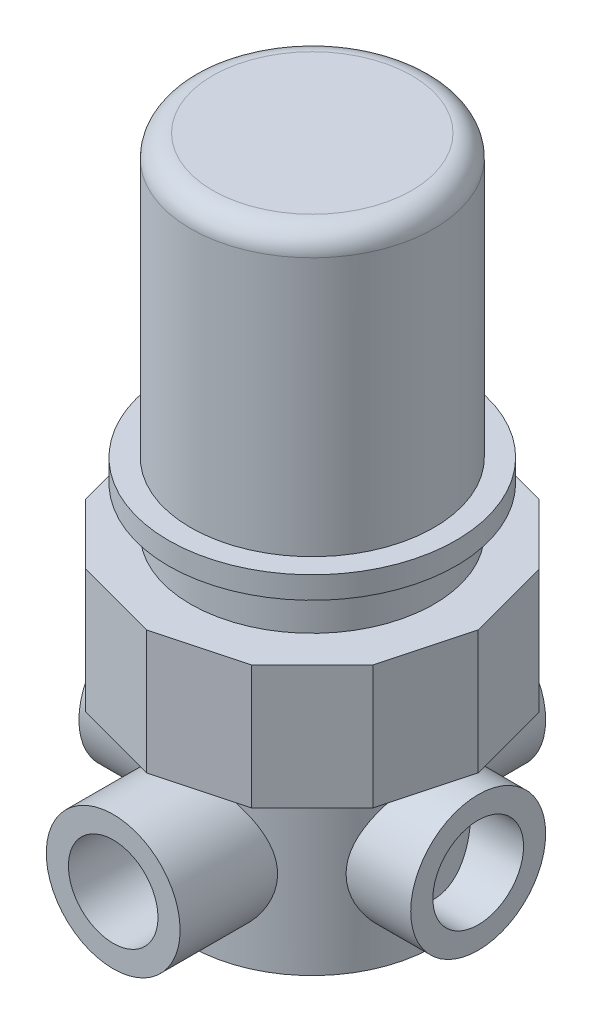
from build123d import *

# Parameters (mm, degrees)
CUT_EXTRUDE1_START       = -14.224
CUT_EXTRUDE1_DEPTH       = 14.224
SKETCH3_R                = 7.6835
SKETCH3_R_2              = 5.1435
BOSS_EXTRUDE1_DEPTH      = 8.89
BOSS_EXTRUDE1_DEPTH_BACK = 8.89
BOSS_EXTRUDE2_START      = -2.344817
SKETCH4_R                = 7.747
SKETCH4_R_2              = 5.207
BOSS_EXTRUDE2_DEPTH      = 7.424817
CIRPATTERN1_COUNT        = 4
FILLET1_R                = 2.54


with BuildPart() as part:
    # Sketch1 → Revolve1 (revolve)
    with BuildSketch(Plane.XY):
        Polygon((0, 73.914), (13.97, 73.914), (13.97, 41.656), (16.51, 41.656), (16.51, 39.116), (13.97, 39.116), (13.97, 34.036), (19.05, 34.036), (19.05, 19.812), (13.97, 19.812), (13.97, 0), (0, 0), align=None)
    revolve(axis=Axis((0, 73.914, 0), (0, -1, 0)))

    # Sketch2 → Cut-Extrude1 (cut)
    with BuildSketch(Plane(origin=(0, 34.036, 0), x_dir=(1, 0, 0), z_dir=(0, 1, 0)).offset(CUT_EXTRUDE1_START)):
        with BuildLine():
            ThreePointArc((9.525, 16.497783942), (4.930502809, 18.400886991), (0, 19.05))
            Line((0, 19.05), (9.525, 16.497783942))
        make_face()
        with BuildLine():
            Line((-9.525, 16.497783942), (0, 19.05))
            ThreePointArc((0, 19.05), (-4.930502809, 18.400886991), (-9.525, 16.497783942))
        make_face()
        with BuildLine():
            Line((-16.497783942, 9.525), (-9.525, 16.497783942))
            ThreePointArc((-9.525, 16.497783942), (-13.470384182, 13.470384182), (-16.497783942, 9.525))
        make_face()
        with BuildLine():
            ThreePointArc((16.497783942, 9.525), (13.470384182, 13.470384182), (9.525, 16.497783942))
            Line((9.525, 16.497783942), (16.497783942, 9.525))
        make_face()
        with BuildLine():
            Line((-19.05, 0), (-16.497783942, 9.525))
            ThreePointArc((-16.497783942, 9.525), (-18.400886991, 4.930502809), (-19.05, 0))
        make_face()
        with BuildLine():
            ThreePointArc((19.05, 0), (18.400886991, 4.930502809), (16.497783942, 9.525))
            Line((16.497783942, 9.525), (19.05, 0))
        make_face()
        with BuildLine():
            Line((-16.497783942, -9.525), (-19.05, 0))
            ThreePointArc((-19.05, 0), (-18.400886991, -4.930502809), (-16.497783942, -9.525))
        make_face()
        with BuildLine():
            ThreePointArc((16.497783942, -9.525), (18.400886991, -4.930502809), (19.05, 0))
            Line((19.05, 0), (16.497783942, -9.525))
        make_face()
        with BuildLine():
            Line((-9.525, -16.497783942), (-16.497783942, -9.525))
            ThreePointArc((-16.497783942, -9.525), (-13.470384182, -13.470384182), (-9.525, -16.497783942))
        make_face()
        with BuildLine():
            ThreePointArc((9.525, -16.497783942), (13.470384182, -13.470384182), (16.497783942, -9.525))
            Line((16.497783942, -9.525), (9.525, -16.497783942))
        make_face()
        with BuildLine():
            Line((0, -19.05), (-9.525, -16.497783942))
            ThreePointArc((-9.525, -16.497783942), (-4.930502809, -18.400886991), (0, -19.05))
        make_face()
        with BuildLine():
            ThreePointArc((0, -19.05), (4.930502809, -18.400886991), (9.525, -16.497783942))
            Line((9.525, -16.497783942), (0, -19.05))
        make_face()
    extrude(amount=CUT_EXTRUDE1_DEPTH, mode=Mode.SUBTRACT)

    # Sketch3 → Boss-Extrude1 (add, two sides)
    with BuildSketch(Plane.XY.offset(13.97)) as boss_extrude1_sk:
        with Locations((0, 9.906)):
            Circle(SKETCH3_R)
        with Locations((0, 9.906)):
            Circle(SKETCH3_R_2, mode=Mode.SUBTRACT)
    extrude(amount=BOSS_EXTRUDE1_DEPTH)
    extrude(boss_extrude1_sk.sketch, amount=-BOSS_EXTRUDE1_DEPTH_BACK)

    # Sketch4 → Boss-Extrude2 (add)
    with BuildSketch(Plane(origin=(13.97, 0, 0), x_dir=(0, 0, -1), z_dir=(1, 0, 0)).offset(BOSS_EXTRUDE2_START)):
        with Locations((0, 9.906)):
            Circle(SKETCH4_R)
        with Locations((0, 9.906)):
            Circle(SKETCH4_R_2, mode=Mode.SUBTRACT)
    boss_extrude2 = extrude(amount=BOSS_EXTRUDE2_DEPTH)

    # CirPattern1: Boss-Extrude2 ×4 about axis, 1 skipped
    cirpattern1_axis = Axis((0, 73.914, 0), (0, -1, 0))
    add([boss_extrude2.rotate(cirpattern1_axis, i * 360 / CIRPATTERN1_COUNT) for i in range(1, CIRPATTERN1_COUNT) if i not in (1,)])

    # Fillet1
    fillet1_edges = [part.edges().sort_by_distance(p)[0] for p in [
        (-13.97, 73.914, 0),
    ]]
    fillet(fillet1_edges, radius=FILLET1_R)


solid = part.part
